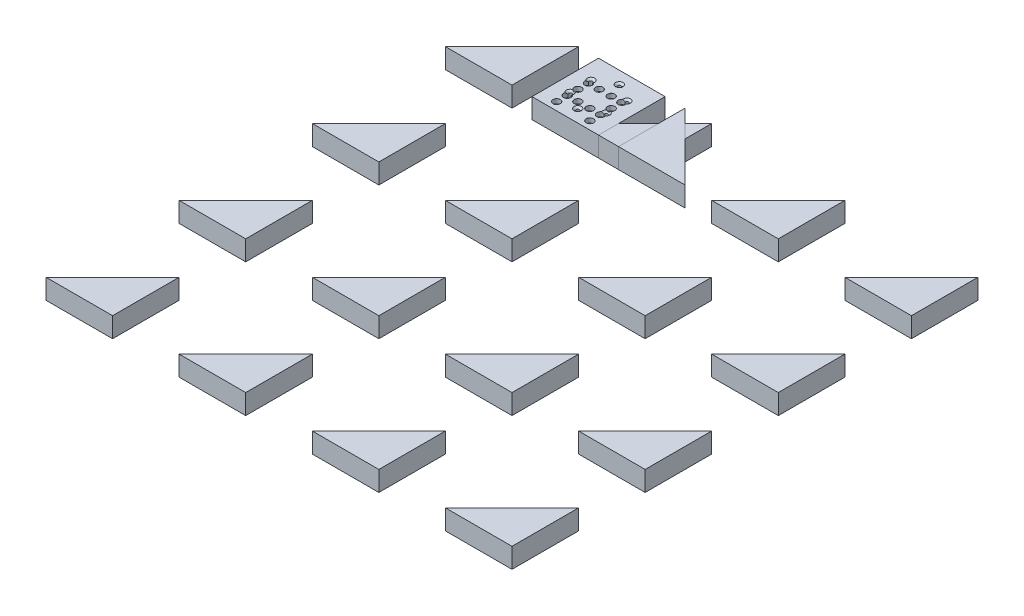
from build123d import *

# Parameters (mm, degrees)
EXTRUDE_1_DEPTH             = 30
SKETCH_1_W                  = 100
SKETCH_1_H                  = 100
EXTRUDE_1_2_DEPTH           = 30
PATTERN_LINEAR_1_COUNT      = 4
PATTERN_LINEAR_1_PITCH      = 16
PATTERN_LINEAR_1_COUNT_DIR2 = 4
PATTERN_LINEAR_1_PITCH_DIR2 = 16
PATTERN_CIRCULAR_1_COUNT    = 6
PATTERN_LINEAR_2_COUNT      = 4
PATTERN_LINEAR_2_PITCH      = 200
PATTERN_LINEAR_2_2_COUNT    = 4
PATTERN_LINEAR_2_2_PITCH    = 200


with BuildPart() as part:
    # 草图1 → 凸台-拉伸1 (new body)
    with BuildSketch(Plane(origin=(0, 0, 0), x_dir=(1, 0, 0), z_dir=(0, 1, 0))):
        Polygon((80, -50), (180, -50), (80, 50), align=None)
    extrude(amount=EXTRUDE_1_DEPTH)


with BuildPart() as body_2:
    # 草图1 → Extrude 1 2 (new body)
    with BuildSketch(Plane(origin=(0, 0, 0), x_dir=(1, 0, 0), z_dir=(0, 1, 0))):
        Rectangle(SKETCH_1_W, SKETCH_1_H)
    extrude(amount=EXTRUDE_1_2_DEPTH)

    # 草图7 → 打孔尺寸(%根据)内六角圆柱头螺钉的类型2 (revolve, cut)
    with BuildSketch(Plane(origin=(-25, 30, -10), x_dir=(0, 0, 1), z_dir=(1, 0, 0))):
        Polygon((0, 0), (0, 30), (3.5, 30), (3.5, 6.8), (5.5, 6.8), (5.5, 0.020977491), (5.525, 0), align=None)
    hole_wizard_2 = revolve(axis=Axis((-25, 36.35, -10), (0, -1, 0)), mode=Mode.SUBTRACT)

    # 草图9 → M6 螺纹孔1 (revolve, cut)
    with BuildSketch(Plane(origin=(0, 30, -31.208457215), x_dir=(0, 0, 1), z_dir=(1, 0, 0))):
        Polygon((0, 0), (0, 30), (2.5, 30), (2.5, 2.538276384), (5.525, 0), align=None)
    hole_wizard_m6_1 = revolve(axis=Axis((0, 36.35, -31.208457215), (0, -1, 0)), mode=Mode.SUBTRACT)

    # 阵列(线性)1: Hole Wizard 2 4 × 4, 10 skipped
    with Locations(*[(i * PATTERN_LINEAR_1_PITCH, 0, j * PATTERN_LINEAR_1_PITCH_DIR2) for i in range(PATTERN_LINEAR_1_COUNT) for j in range(PATTERN_LINEAR_1_COUNT_DIR2) if (i, j) not in ((0, 0), (1, 1), (1, 3), (2, 0), (2, 1), (2, 2), (2, 3), (3, 0), (3, 1), (3, 2), (3, 3))]):
        add(hole_wizard_2, mode=Mode.SUBTRACT)

    # 阵列(圆周)1: M6 螺纹孔1 ×6 about axis
    pattern_circular_1_axis = Axis((0, 0, 0), (0, 1, 0))
    for i in range(1, PATTERN_CIRCULAR_1_COUNT):
        add(hole_wizard_m6_1.rotate(pattern_circular_1_axis, i * 360 / PATTERN_CIRCULAR_1_COUNT), mode=Mode.SUBTRACT)

    # 镜向4 copy 1 sketch → 镜向4 copy 1 (revolve, cut)
    with BuildSketch(Plane(origin=(25, 30, 6), x_dir=(0, 0, 1), z_dir=(-1, 0, 0))):
        Polygon((0, 0), (0, -30), (3.5, -30), (3.5, -6.8), (5.5, -6.8), (5.5, -0.020977491), (5.525, 0), align=None)
    revolve(axis=Axis((25, 36.35, 6), (0, 1, 0)), mode=Mode.SUBTRACT)

    # 镜向4 copy 2 sketch → 镜向4 copy 2 (revolve, cut)
    with BuildSketch(Plane(origin=(25, 30, 22), x_dir=(0, 0, 1), z_dir=(-1, 0, 0))):
        Polygon((0, 0), (0, -30), (3.5, -30), (3.5, -6.8), (5.5, -6.8), (5.5, -0.020977491), (5.525, 0), align=None)
    revolve(axis=Axis((25, 36.35, 22), (0, 1, 0)), mode=Mode.SUBTRACT)

    # 镜向4 copy 3 sketch → 镜向4 copy 3 (revolve, cut)
    with BuildSketch(Plane(origin=(25, 30, 38), x_dir=(0, 0, 1), z_dir=(-1, 0, 0))):
        Polygon((0, 0), (0, -30), (3.5, -30), (3.5, -6.8), (5.5, -6.8), (5.5, -0.020977491), (5.525, 0), align=None)
    revolve(axis=Axis((25, 36.35, 38), (0, 1, 0)), mode=Mode.SUBTRACT)

    # 镜向4 copy 4 sketch → 镜向4 copy 4 (revolve, cut)
    with BuildSketch(Plane(origin=(9, 30, -10), x_dir=(0, 0, 1), z_dir=(-1, 0, 0))):
        Polygon((0, 0), (0, -30), (3.5, -30), (3.5, -6.8), (5.5, -6.8), (5.5, -0.020977491), (5.525, 0), align=None)
    revolve(axis=Axis((9, 36.35, -10), (0, 1, 0)), mode=Mode.SUBTRACT)

    # 镜向4 copy 5 sketch → 镜向4 copy 5 (revolve, cut)
    with BuildSketch(Plane(origin=(9, 30, 22), x_dir=(0, 0, 1), z_dir=(-1, 0, 0))):
        Polygon((0, 0), (0, -30), (3.5, -30), (3.5, -6.8), (5.5, -6.8), (5.5, -0.020977491), (5.525, 0), align=None)
    revolve(axis=Axis((9, 36.35, 22), (0, 1, 0)), mode=Mode.SUBTRACT)

    # 镜向4 copy 6 sketch → 镜向4 copy 6 (revolve, cut)
    with BuildSketch(Plane(origin=(25, 30, -10), x_dir=(0, 0, 1), z_dir=(-1, 0, 0))):
        Polygon((0, 0), (0, -30), (3.5, -30), (3.5, -6.8), (5.5, -6.8), (5.5, -0.020977491), (5.525, 0), align=None)
    revolve(axis=Axis((25, 36.35, -10), (0, 1, 0)), mode=Mode.SUBTRACT)


with BuildPart() as body_3:
    # 镜向6: mirrored copy
    add(part.part.mirror(Plane(origin=(0, 0, 0), x_dir=(0, 0, 1), z_dir=(1, 0, 0))))


with BuildPart() as pattern_linear_2_1:
    # 阵列(线性)2: pattern copy
    add(body_3.part.moved(Location(Vector(1, 0, 0) * (1 * PATTERN_LINEAR_2_PITCH))))


with BuildPart() as pattern_linear_2_2:
    # 阵列(线性)2: pattern copy
    add(body_3.part.moved(Location(Vector(1, 0, 0) * (2 * PATTERN_LINEAR_2_PITCH))))


with BuildPart() as pattern_linear_2_3:
    # 阵列(线性)2: pattern copy
    add(body_3.part.moved(Location(Vector(1, 0, 0) * (3 * PATTERN_LINEAR_2_PITCH))))


with BuildPart() as pattern_linear_2_2_1:
    # Pattern Linear 2 2: pattern copy
    add(body_3.part.moved(Location(Vector(0, 0, 1) * (1 * PATTERN_LINEAR_2_2_PITCH))))


with BuildPart() as pattern_linear_2_2_2:
    # Pattern Linear 2 2: pattern copy
    add(body_3.part.moved(Location(Vector(0, 0, 1) * (2 * PATTERN_LINEAR_2_2_PITCH))))


with BuildPart() as pattern_linear_2_2_3:
    # Pattern Linear 2 2: pattern copy
    add(body_3.part.moved(Location(Vector(0, 0, 1) * (3 * PATTERN_LINEAR_2_2_PITCH))))


with BuildPart() as pattern_linear_2_2_4:
    # Pattern Linear 2 2: pattern copy
    add(pattern_linear_2_1.part.moved(Location(Vector(0, 0, 1) * (1 * PATTERN_LINEAR_2_2_PITCH))))


with BuildPart() as pattern_linear_2_2_5:
    # Pattern Linear 2 2: pattern copy
    add(pattern_linear_2_1.part.moved(Location(Vector(0, 0, 1) * (2 * PATTERN_LINEAR_2_2_PITCH))))


with BuildPart() as pattern_linear_2_2_6:
    # Pattern Linear 2 2: pattern copy
    add(pattern_linear_2_1.part.moved(Location(Vector(0, 0, 1) * (3 * PATTERN_LINEAR_2_2_PITCH))))


with BuildPart() as pattern_linear_2_2_7:
    # Pattern Linear 2 2: pattern copy
    add(pattern_linear_2_2.part.moved(Location(Vector(0, 0, 1) * (1 * PATTERN_LINEAR_2_2_PITCH))))


with BuildPart() as pattern_linear_2_2_8:
    # Pattern Linear 2 2: pattern copy
    add(pattern_linear_2_2.part.moved(Location(Vector(0, 0, 1) * (2 * PATTERN_LINEAR_2_2_PITCH))))


with BuildPart() as pattern_linear_2_2_9:
    # Pattern Linear 2 2: pattern copy
    add(pattern_linear_2_2.part.moved(Location(Vector(0, 0, 1) * (3 * PATTERN_LINEAR_2_2_PITCH))))


with BuildPart() as pattern_linear_2_2_10:
    # Pattern Linear 2 2: pattern copy
    add(pattern_linear_2_3.part.moved(Location(Vector(0, 0, 1) * (1 * PATTERN_LINEAR_2_2_PITCH))))


with BuildPart() as pattern_linear_2_2_11:
    # Pattern Linear 2 2: pattern copy
    add(pattern_linear_2_3.part.moved(Location(Vector(0, 0, 1) * (2 * PATTERN_LINEAR_2_2_PITCH))))


with BuildPart() as pattern_linear_2_2_12:
    # Pattern Linear 2 2: pattern copy
    add(pattern_linear_2_3.part.moved(Location(Vector(0, 0, 1) * (3 * PATTERN_LINEAR_2_2_PITCH))))


solid = Compound([part.part, body_2.part, body_3.part, pattern_linear_2_1.part, pattern_linear_2_2.part, pattern_linear_2_3.part, pattern_linear_2_2_1.part, pattern_linear_2_2_2.part, pattern_linear_2_2_3.part, pattern_linear_2_2_4.part, pattern_linear_2_2_5.part, pattern_linear_2_2_6.part, pattern_linear_2_2_7.part, pattern_linear_2_2_8.part, pattern_linear_2_2_9.part, pattern_linear_2_2_10.part, pattern_linear_2_2_11.part, pattern_linear_2_2_12.part])
